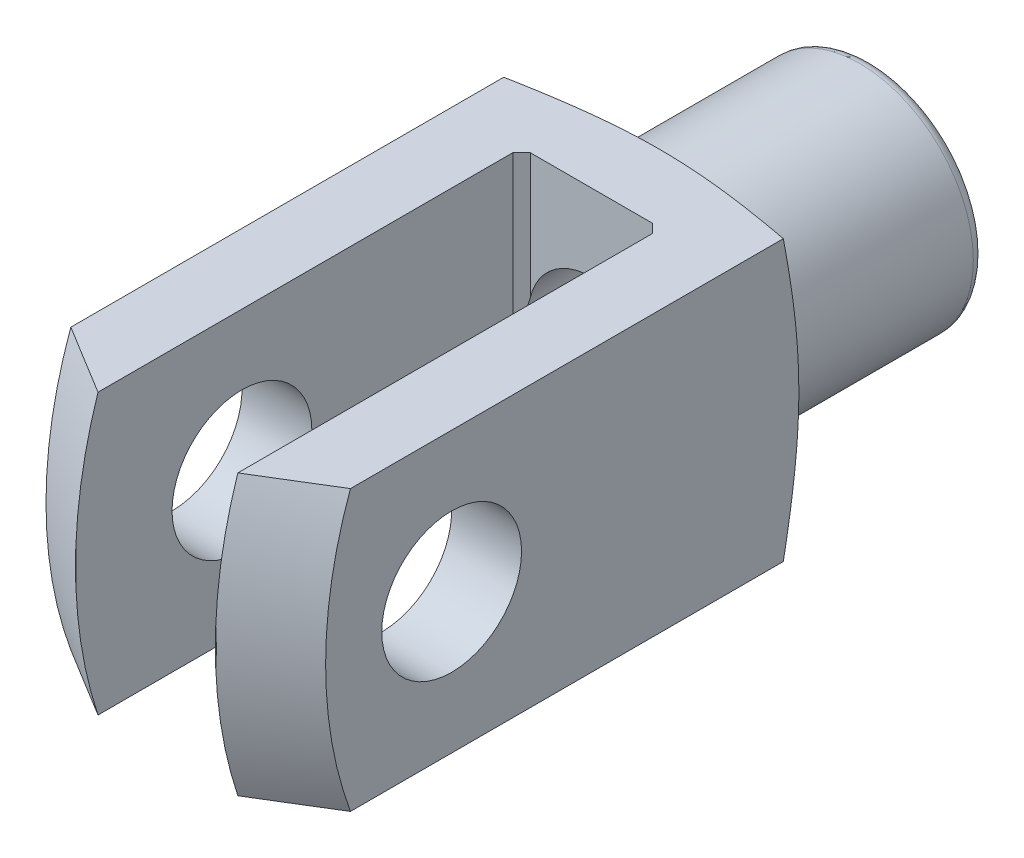
from build123d import *

# Parameters (mm, degrees)
CUT_EXTRUDE1_DEPTH           = 33
CUT_EXTRUDE1_DEPTH_BACK      = 33
CUT_EXTRUDE2_DEPTH           = 33
CUT_EXTRUDE2_DEPTH_BACK      = 33
CUT_EXTRUDE3_DEPTH           = 33
CUT_EXTRUDE3_DEPTH_BACK      = 33
SKETCH5_W                    = 39.5
SKETCH5_H                    = 8
CUT_REVOLVE3_ANGLE           = 90
CUT_REVOLVE3_OTHER_WAY_ANGLE = 90


with BuildPart() as part:
    # Sketch1 → Revolve1 (revolve)
    with BuildSketch(Plane(origin=(0, 0, 0), x_dir=(0, 0, -1), z_dir=(1, 0, 0))):
        with BuildLine():
            Line((-19, 0), (-19, 32))
            Line((-19, 32), (35.444863729, 32))
            Line((35.444863729, 32), (40, 15))
            ThreePointArc((40, 15), (40.585786438, 13.585786438), (42, 13))
            Line((42, 13), (62.7, 13))
            ThreePointArc((62.7, 13), (63.619238816, 12.619238816), (64, 11.7))
            Line((64, 11.7), (64, 0))
            Line((64, 0), (-19, 0))
        make_face()
    revolve(axis=Axis((0, 0, -64), (0, 0, 1)))

    # Sketch2 → Cut-Extrude1 (cut, two sides)
    with BuildSketch(Plane(origin=(0, 0, 0), x_dir=(1, 0, 0), z_dir=(0, 1, 0))) as cut_extrude1_sk:
        Polygon((-8, 31), (-8, -20), (8, -20), (8, 31), (7, 32), (-7, 32), align=None)
    extrude(amount=CUT_EXTRUDE1_DEPTH, mode=Mode.SUBTRACT)
    extrude(cut_extrude1_sk.sketch, amount=-CUT_EXTRUDE1_DEPTH_BACK, mode=Mode.SUBTRACT)

    # Sketch3 → Cut-Extrude2 (cut, two sides)
    with BuildSketch(Plane(origin=(0, 0, 0), x_dir=(0, 0, -1), z_dir=(1, 0, 0))) as cut_extrude2_sk:
        Polygon((-52, -48), (64, -48), (64, -16), (-20, -16), (-20, 16), (64, 16), (64, 48), (-52, 48), align=None)
    extrude(amount=CUT_EXTRUDE2_DEPTH, mode=Mode.SUBTRACT)
    extrude(cut_extrude2_sk.sketch, amount=-CUT_EXTRUDE2_DEPTH_BACK, mode=Mode.SUBTRACT)

    # Sketch4 → Cut-Extrude3 (cut, two sides)
    with BuildSketch(Plane(origin=(0, 0, 0), x_dir=(1, 0, 0), z_dir=(0, 1, 0))) as cut_extrude3_sk:
        Polygon((-48, -52), (48, -52), (48, 64), (16, 64), (16, -20), (-16, -20), (-16, 64), (-48, 64), align=None)
    extrude(amount=CUT_EXTRUDE3_DEPTH, mode=Mode.SUBTRACT)
    extrude(cut_extrude3_sk.sketch, amount=-CUT_EXTRUDE3_DEPTH_BACK, mode=Mode.SUBTRACT)

    # Sketch5 → Cut-Revolve1 (revolve, cut)
    with BuildSketch(Plane.XY):
        with Locations((0, 4)):
            Rectangle(SKETCH5_W, SKETCH5_H)
    revolve(axis=Axis((19.75, 0, 0), (-1, 0, 0)), mode=Mode.SUBTRACT)

    # Sketch6 → Cut-Revolve2 (revolve, cut)
    with BuildSketch(Plane(origin=(0, 0, 0), x_dir=(0, 0, -1), z_dir=(1, 0, 0))):
        Polygon((30.9, 0), (30.9, 7.188), (63.288, 7.188), (64.1, 8), (64.1, 0), align=None)
    revolve(axis=Axis((0, 0, -64.1), (0, 0, 1)), mode=Mode.SUBTRACT)

    # Sketch7 → Cut-Revolve3 (revolve, cut)
    with BuildSketch(Plane(origin=(0, 0, 0), x_dir=(1, 0, 0), z_dir=(0, 1, 0))):
        Polygon((-19, -49.64182924), (0, -60.611484355), (19, -49.64182924), (19, -12.691412012), (0, -23.661067127), (-19, -12.691412012), align=None)
    revolve(axis=Axis((-19, 0, -32), (1, 0, 0)), revolution_arc=CUT_REVOLVE3_ANGLE, mode=Mode.SUBTRACT)

    # Sketch7 → Cut-Revolve3 other way (revolve, cut)
    with BuildSketch(Plane(origin=(0, 0, 0), x_dir=(1, 0, 0), z_dir=(0, 1, 0))):
        Polygon((-19, -49.64182924), (0, -60.611484355), (19, -49.64182924), (19, -12.691412012), (0, -23.661067127), (-19, -12.691412012), align=None)
    revolve(axis=Axis((-19, 0, -32), (-1, 0, 0)), revolution_arc=CUT_REVOLVE3_OTHER_WAY_ANGLE, mode=Mode.SUBTRACT)


solid = part.part
